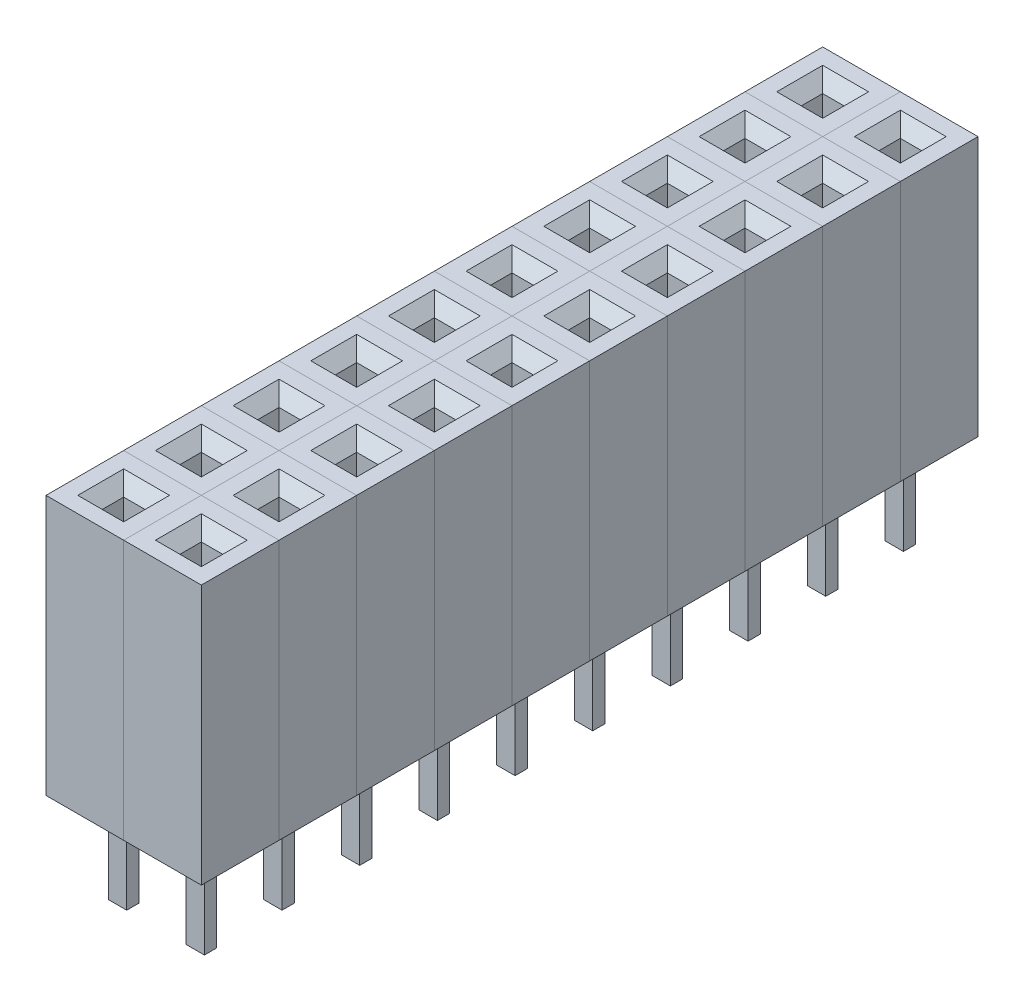
from build123d import *

# Parameters (mm, degrees)
SKETCH_1_W               = 2.54
SKETCH_1_H               = 2.54
EXTRUDE_1_DEPTH          = 8.5
SKETCH_2_W               = 0.7
SKETCH_2_H               = 0.7
CUT_EXTRUDE_1_DEPTH      = 1
CUT_EXTRUDE_1_DEPTH_BACK = 8
CHAMFER_1_SIZE           = 0.4
SKETCH_3_W               = 0.6
SKETCH_3_H               = 0.4
EXTRUDE_2_DEPTH          = 3
PATTERN_LINEAR_1_COUNT   = 2
PATTERN_LINEAR_1_PITCH   = 2.54
LPATTERN1_COUNT          = 10
LPATTERN1_PITCH          = 2.54


with BuildPart() as part:
    # Эскиз1 → Бобышка-Вытянуть1 (new body)
    with BuildSketch(Plane(origin=(0, 0, 0), x_dir=(1, 0, 0), z_dir=(0, 1, 0))):
        Rectangle(SKETCH_1_W, SKETCH_1_H)
    extrude(amount=EXTRUDE_1_DEPTH)

    # Эскиз2 → Вырез-Вытянуть1 (cut, two sides)
    with BuildSketch(Plane(origin=(0, 8.5, 0), x_dir=(1, 0, 0), z_dir=(0, 1, 0))) as cut_extrude_1_sk:
        Rectangle(SKETCH_2_W, SKETCH_2_H)
    extrude(amount=CUT_EXTRUDE_1_DEPTH, mode=Mode.SUBTRACT)
    extrude(cut_extrude_1_sk.sketch, amount=-CUT_EXTRUDE_1_DEPTH_BACK, mode=Mode.SUBTRACT)

    # Фаска1
    chamfer_1_edges = [part.edges().sort_by_distance(p)[0] for p in [
        (0, 8.5, 0.35),
        (0.35, 8.5, 0),
        (0, 8.5, -0.35),
        (-0.35, 8.5, 0),
    ]]
    chamfer(chamfer_1_edges, length=CHAMFER_1_SIZE)

    # Эскиз3 → Бобышка-Вытянуть2 (add)
    with BuildSketch(Plane.XZ):
        Rectangle(SKETCH_3_W, SKETCH_3_H)
    extrude(amount=EXTRUDE_2_DEPTH)


with BuildPart() as pattern_linear_1_1:
    # Линейный массив1: pattern copy
    add(part.part.moved(Location(Vector(1, 0, 0) * (1 * PATTERN_LINEAR_1_PITCH))))


with BuildPart() as lpattern1_1:
    # LPattern1: pattern copy
    add(pattern_linear_1_1.part.moved(Location(Vector(0, 0, -1) * (1 * LPATTERN1_PITCH))))


with BuildPart() as lpattern1_2:
    # LPattern1: pattern copy
    add(pattern_linear_1_1.part.moved(Location(Vector(0, 0, -1) * (2 * LPATTERN1_PITCH))))


with BuildPart() as lpattern1_3:
    # LPattern1: pattern copy
    add(pattern_linear_1_1.part.moved(Location(Vector(0, 0, -1) * (3 * LPATTERN1_PITCH))))


with BuildPart() as lpattern1_4:
    # LPattern1: pattern copy
    add(pattern_linear_1_1.part.moved(Location(Vector(0, 0, -1) * (4 * LPATTERN1_PITCH))))


with BuildPart() as lpattern1_5:
    # LPattern1: pattern copy
    add(pattern_linear_1_1.part.moved(Location(Vector(0, 0, -1) * (5 * LPATTERN1_PITCH))))


with BuildPart() as lpattern1_6:
    # LPattern1: pattern copy
    add(pattern_linear_1_1.part.moved(Location(Vector(0, 0, -1) * (6 * LPATTERN1_PITCH))))


with BuildPart() as lpattern1_7:
    # LPattern1: pattern copy
    add(pattern_linear_1_1.part.moved(Location(Vector(0, 0, -1) * (7 * LPATTERN1_PITCH))))


with BuildPart() as lpattern1_8:
    # LPattern1: pattern copy
    add(pattern_linear_1_1.part.moved(Location(Vector(0, 0, -1) * (8 * LPATTERN1_PITCH))))


with BuildPart() as lpattern1_9:
    # LPattern1: pattern copy
    add(pattern_linear_1_1.part.moved(Location(Vector(0, 0, -1) * (9 * LPATTERN1_PITCH))))


with BuildPart() as lpattern1_10:
    # LPattern1: pattern copy
    add(part.part.moved(Location(Vector(0, 0, -1) * (1 * LPATTERN1_PITCH))))


with BuildPart() as lpattern1_11:
    # LPattern1: pattern copy
    add(part.part.moved(Location(Vector(0, 0, -1) * (2 * LPATTERN1_PITCH))))


with BuildPart() as lpattern1_12:
    # LPattern1: pattern copy
    add(part.part.moved(Location(Vector(0, 0, -1) * (3 * LPATTERN1_PITCH))))


with BuildPart() as lpattern1_13:
    # LPattern1: pattern copy
    add(part.part.moved(Location(Vector(0, 0, -1) * (4 * LPATTERN1_PITCH))))


with BuildPart() as lpattern1_14:
    # LPattern1: pattern copy
    add(part.part.moved(Location(Vector(0, 0, -1) * (5 * LPATTERN1_PITCH))))


with BuildPart() as lpattern1_15:
    # LPattern1: pattern copy
    add(part.part.moved(Location(Vector(0, 0, -1) * (6 * LPATTERN1_PITCH))))


with BuildPart() as lpattern1_16:
    # LPattern1: pattern copy
    add(part.part.moved(Location(Vector(0, 0, -1) * (7 * LPATTERN1_PITCH))))


with BuildPart() as lpattern1_17:
    # LPattern1: pattern copy
    add(part.part.moved(Location(Vector(0, 0, -1) * (8 * LPATTERN1_PITCH))))


with BuildPart() as lpattern1_18:
    # LPattern1: pattern copy
    add(part.part.moved(Location(Vector(0, 0, -1) * (9 * LPATTERN1_PITCH))))


solid = Compound([part.part, pattern_linear_1_1.part, lpattern1_1.part, lpattern1_2.part, lpattern1_3.part, lpattern1_4.part, lpattern1_5.part, lpattern1_6.part, lpattern1_7.part, lpattern1_8.part, lpattern1_9.part, lpattern1_10.part, lpattern1_11.part, lpattern1_12.part, lpattern1_13.part, lpattern1_14.part, lpattern1_15.part, lpattern1_16.part, lpattern1_17.part, lpattern1_18.part])
